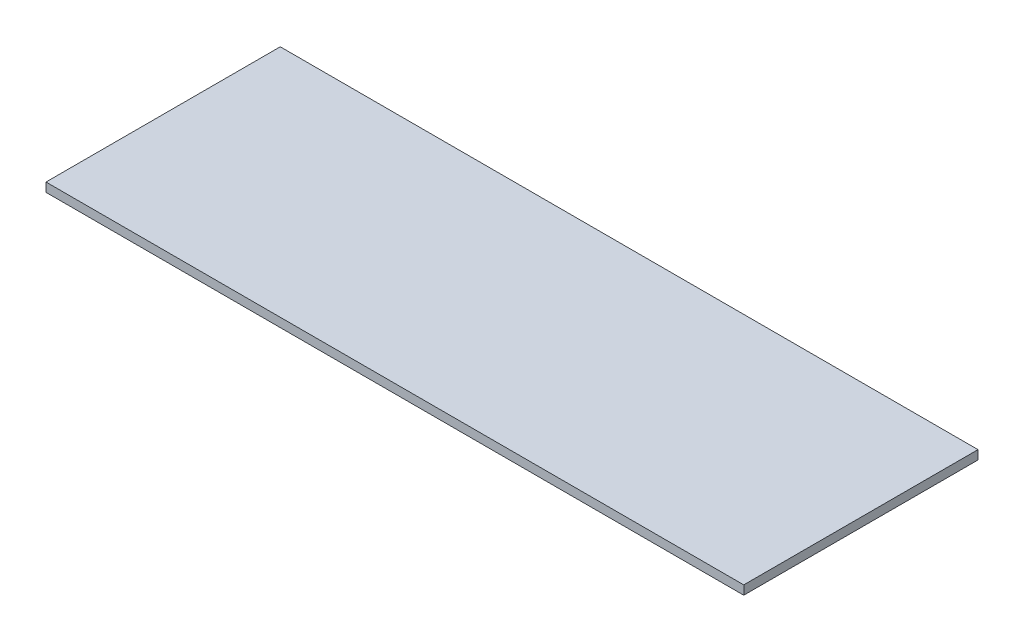
from build123d import *

# Parameters (mm, degrees)
SKETCH1_W           = 1400
SKETCH1_H           = 470
BOSS_EXTRUDE1_DEPTH = 18


with BuildPart() as part:
    # Sketch1 → Boss-Extrude1 (new body)
    with BuildSketch(Plane(origin=(0, 0, 0), x_dir=(1, 0, 0), z_dir=(0, 1, 0))):
        with Locations((700, 235)):
            Rectangle(SKETCH1_W, SKETCH1_H)
    extrude(amount=BOSS_EXTRUDE1_DEPTH)


solid = part.part
